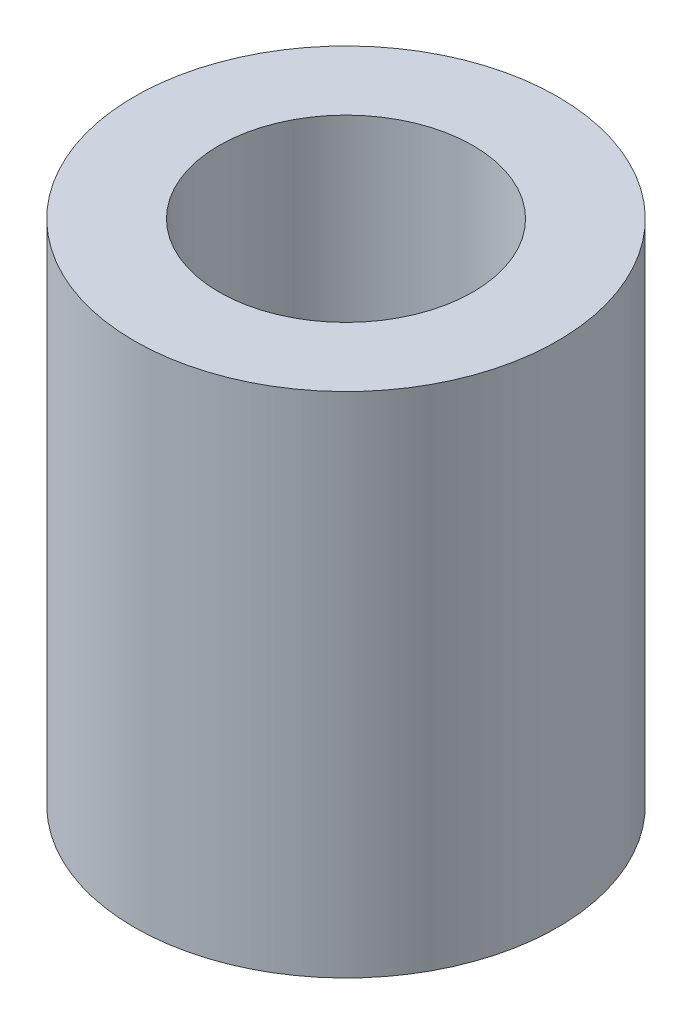
from build123d import *

# Parameters (mm, degrees)
SKETCH1_R           = 5
SKETCH1_R_2         = 3
BOSS_EXTRUDE1_DEPTH = 12


with BuildPart() as part:
    # Sketch1 → Boss-Extrude1 (new body)
    with BuildSketch(Plane(origin=(0, 0, 0), x_dir=(1, 0, 0), z_dir=(0, 1, 0))):
        Circle(SKETCH1_R)
        Circle(SKETCH1_R_2, mode=Mode.SUBTRACT)
    extrude(amount=BOSS_EXTRUDE1_DEPTH)


solid = part.part
